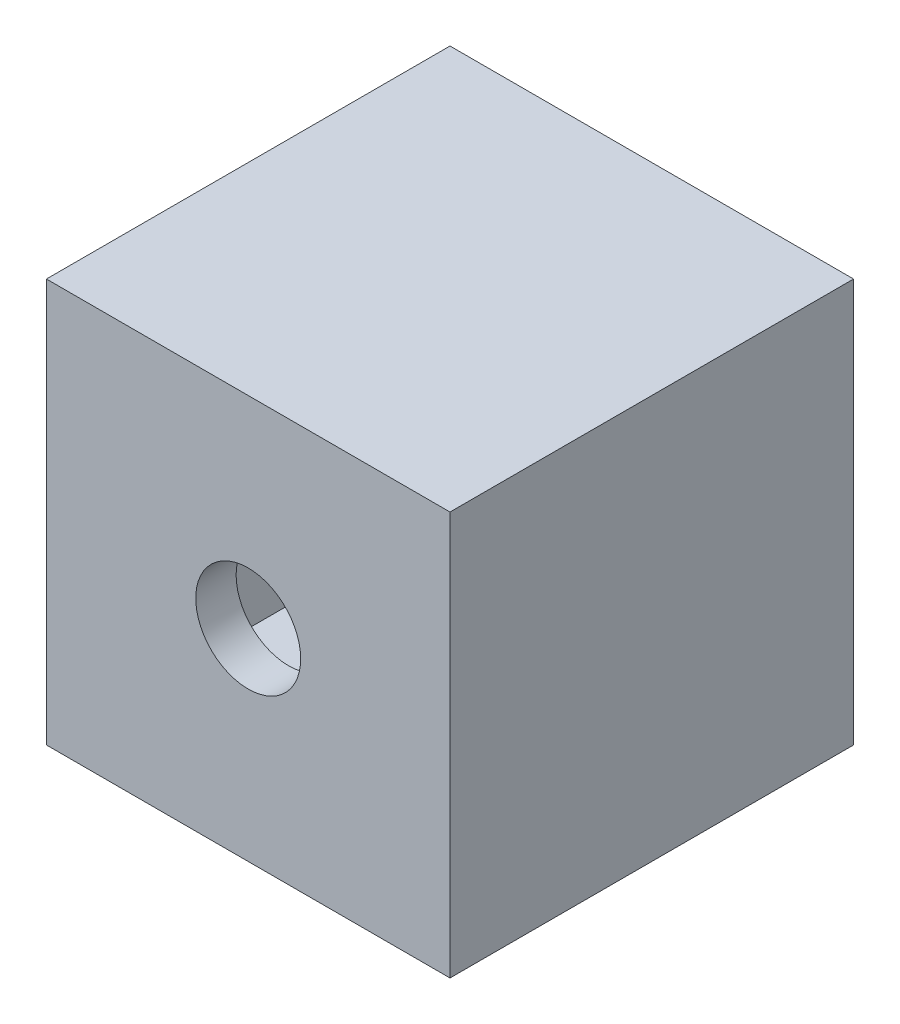
from build123d import *

# Parameters (mm, degrees)
SKETCH5_W           = 200
SKETCH5_H           = 200
BOSS_EXTRUDE2_DEPTH = 200
SHELL2_T            = -20
SKETCH6_R           = 26
CUT_EXTRUDE2_DEPTH  = 51.6


with BuildPart() as part:
    # Sketch5 → Boss-Extrude2 (new body)
    with BuildSketch(Plane.XY):
        Rectangle(SKETCH5_W, SKETCH5_H)
    extrude(amount=BOSS_EXTRUDE2_DEPTH)

    # Shell2
    shell2_openings = [part.faces().sort_by_distance(p)[0] for p in [
        (0, 0, 0),
    ]]
    offset(amount=SHELL2_T, openings=shell2_openings, kind=Kind.INTERSECTION)

    # Sketch6 → Cut-Extrude2 (cut)
    with BuildSketch(Plane.XY.offset(200)):
        Circle(SKETCH6_R)
    extrude(amount=-CUT_EXTRUDE2_DEPTH, mode=Mode.SUBTRACT)


solid = part.part
